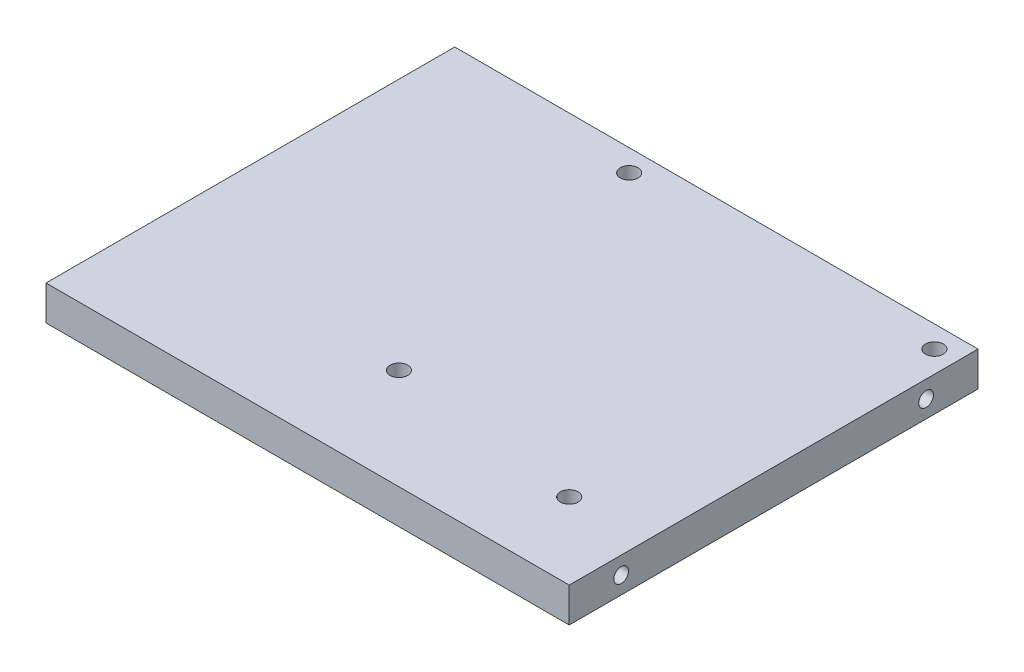
from build123d import *

# Parameters (mm, degrees)
SKETCH1_W           = 96
SKETCH1_H           = 75
BOSS_EXTRUDE1_DEPTH = 6.35
SKETCH2_R           = 1.63195
CUT_EXTRUDE1_DEPTH  = 6.35
SKETCH3_R           = 1.35255
CUT_EXTRUDE2_DEPTH  = 9.525
SKETCH4_R           = 1.35255
CUT_EXTRUDE3_DEPTH  = 9.525


with BuildPart() as part:
    # Sketch1 → Boss-Extrude1 (new body)
    with BuildSketch(Plane(origin=(0, -8, 0), x_dir=(-1, 0, 0), z_dir=(0, -1, 0))):
        with Locations((-48, 37.5)):
            Rectangle(SKETCH1_W, SKETCH1_H)
    extrude(amount=-BOSS_EXTRUDE1_DEPTH)

    # Sketch2 → Cut-Extrude1 (cut)
    with BuildSketch(Plane.XZ.offset(8)):
        with Locations((36, -71)):
            Circle(SKETCH2_R)
        with Locations((46.25, -18.5)):
            Circle(SKETCH2_R)
        with Locations((82, -14)):
            Circle(SKETCH2_R)
        with Locations((92, -71)):
            Circle(SKETCH2_R)
    extrude(amount=-CUT_EXTRUDE1_DEPTH, mode=Mode.SUBTRACT)

    # Sketch3 → Cut-Extrude2 (cut)
    with BuildSketch(Plane.ZY):
        with Locations((-65.475, -4.825)):
            Circle(SKETCH3_R)
        with Locations((-9.525, -4.825)):
            Circle(SKETCH3_R)
    extrude(amount=-CUT_EXTRUDE2_DEPTH, mode=Mode.SUBTRACT)

    # Sketch4 → Cut-Extrude3 (cut)
    with BuildSketch(Plane(origin=(96, 0, 0), x_dir=(0, 0, -1), z_dir=(1, 0, 0))):
        with Locations((65.475, -4.825)):
            Circle(SKETCH4_R)
        with Locations((9.525, -4.825)):
            Circle(SKETCH4_R)
    extrude(amount=-CUT_EXTRUDE3_DEPTH, mode=Mode.SUBTRACT)


solid = part.part
